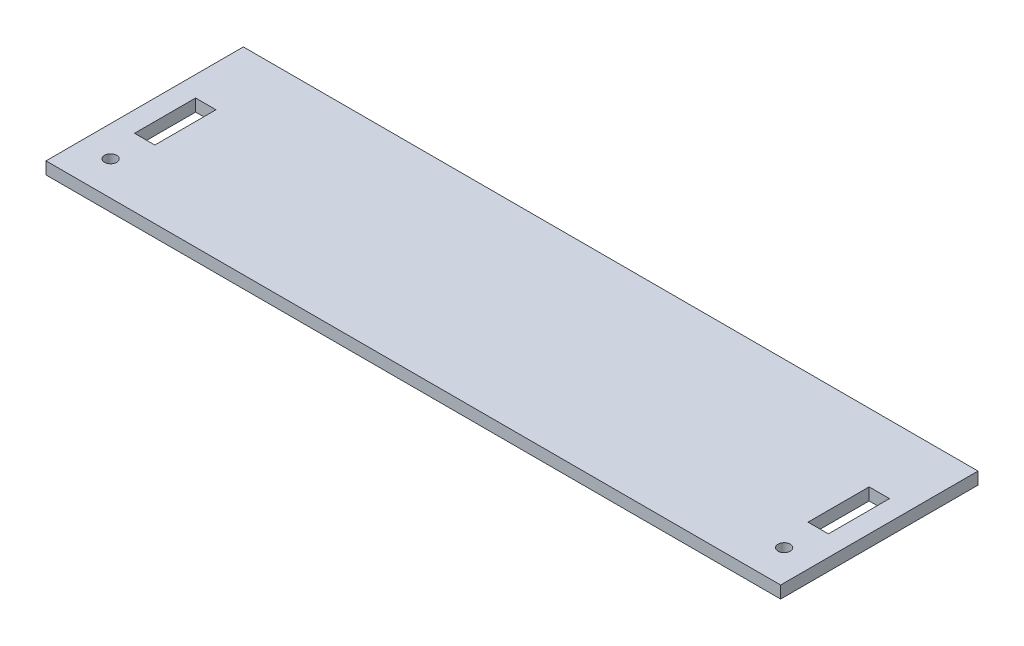
from build123d import *

# Parameters (mm, degrees)
SCHIZZO1_W                   = 180.34
SCHIZZO1_H                   = 48.45
ESTRUSIONE_ESTRUSIONE1_DEPTH = 3
SCHIZZO2_R                   = 1.5
SCHIZZO2_W                   = 5
SCHIZZO2_H                   = 15
TAGLIO_ESTRUSIONE1_DEPTH     = 4


with BuildPart() as part:
    # Schizzo1 → Estrusione-Estrusione1 (new body)
    with BuildSketch(Plane(origin=(0, 0, 0), x_dir=(1, 0, 0), z_dir=(0, 1, 0))):
        Rectangle(SCHIZZO1_W, SCHIZZO1_H)
    extrude(amount=ESTRUSIONE_ESTRUSIONE1_DEPTH)

    # Schizzo2 → Taglio-Estrusione1 (cut, through all)
    with BuildSketch(Plane(origin=(0, 0, 0), x_dir=(1, 0, 0), z_dir=(0, 1, 0))):
        with Locations((-82.67, -15.8625)):
            Circle(SCHIZZO2_R)
        with Locations((82.67, -15.8625)):
            Circle(SCHIZZO2_R)
        with Locations((-82.67, 0)):
            Rectangle(SCHIZZO2_W, SCHIZZO2_H)
        with Locations((82.67, 0)):
            Rectangle(SCHIZZO2_W, SCHIZZO2_H)
    extrude(amount=TAGLIO_ESTRUSIONE1_DEPTH, mode=Mode.SUBTRACT)


solid = part.part
